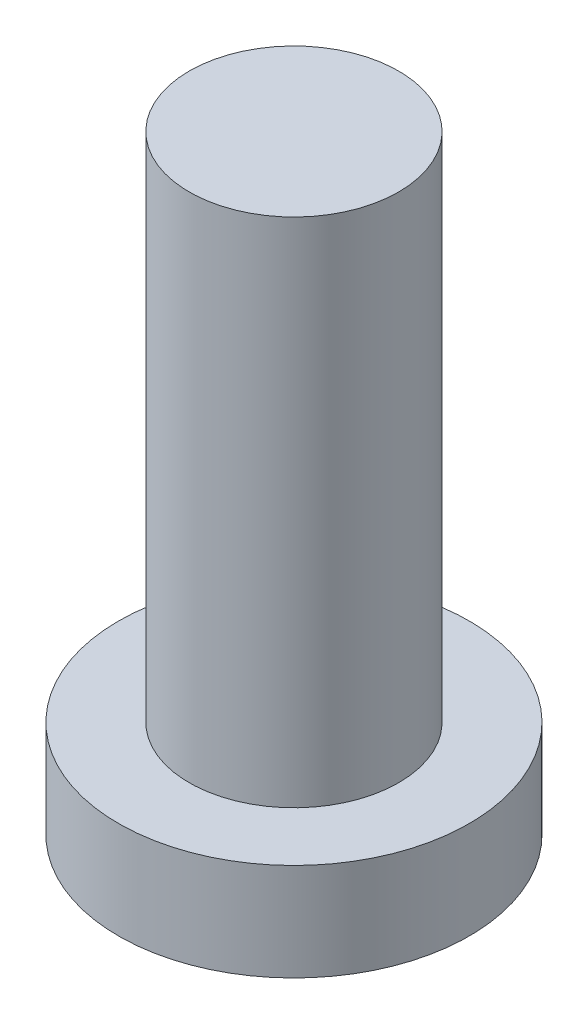
from build123d import *


with BuildPart() as part:
    # Sketch1 → Revolve1 (revolve)
    with BuildSketch(Plane.XY, mode=Mode.PRIVATE) as revolve1_sk:
        Polygon((0, 0), (1.8288, 0), (1.8288, 1.016), (1.0922, 1.016), (1.0922, 6.35), (0, 6.35), align=None)
    revolve(revolve1_sk.sketch.rotate(Axis((0, 48.210572936, 0), (0, -1, 0)), 180), axis=Axis((0, 48.210572936, 0), (0, -1, 0)))  # turned: the seam where the file's is


solid = part.part
